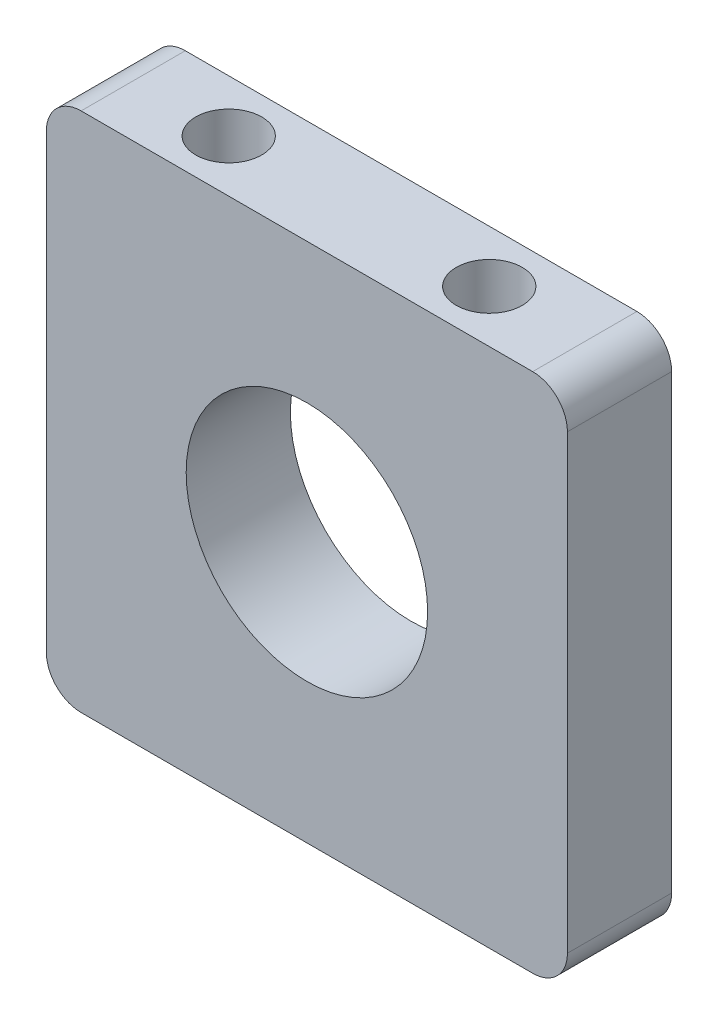
from build123d import *

# Parameters (mm, degrees)
SKETCH1_W           = 38.1
SKETCH1_H           = 38.1
SKETCH1_R           = 8.8265
BOSS_EXTRUDE1_DEPTH = 7.62
FILLET1_R           = 2.54
SKETCH2_R           = 2.413
CUT_EXTRUDE1_DEPTH  = 7.62
SKETCH3_R           = 2.413
CUT_EXTRUDE2_DEPTH  = 7.62


with BuildPart() as part:
    # Sketch1 → Boss-Extrude1 (new body)
    with BuildSketch(Plane.XY):
        Rectangle(SKETCH1_W, SKETCH1_H)
        Circle(SKETCH1_R, mode=Mode.SUBTRACT)
    extrude(amount=BOSS_EXTRUDE1_DEPTH)

    # Fillet1
    fillet1_edges = [part.edges().sort_by_distance(p)[0] for p in [
        (-19.05, 19.05, 3.81),
        (19.05, 19.05, 3.81),
        (19.05, -19.05, 3.81),
        (-19.05, -19.05, 3.81),
    ]]
    fillet(fillet1_edges, radius=FILLET1_R)

    # Sketch2 → Cut-Extrude1 (cut)
    with BuildSketch(Plane.XZ.offset(19.05)):
        with Locations((9.525, 3.81)):
            Circle(SKETCH2_R)
        with Locations((-9.525, 3.81)):
            Circle(SKETCH2_R)
    extrude(amount=-CUT_EXTRUDE1_DEPTH, mode=Mode.SUBTRACT)

    # Sketch3 → Cut-Extrude2 (cut)
    with BuildSketch(Plane(origin=(0, 19.05, 0), x_dir=(1, 0, 0), z_dir=(0, 1, 0))):
        with Locations((-9.525, -3.81)):
            Circle(SKETCH3_R)
        with Locations((9.525, -3.81)):
            Circle(SKETCH3_R)
    extrude(amount=-CUT_EXTRUDE2_DEPTH, mode=Mode.SUBTRACT)


solid = part.part
